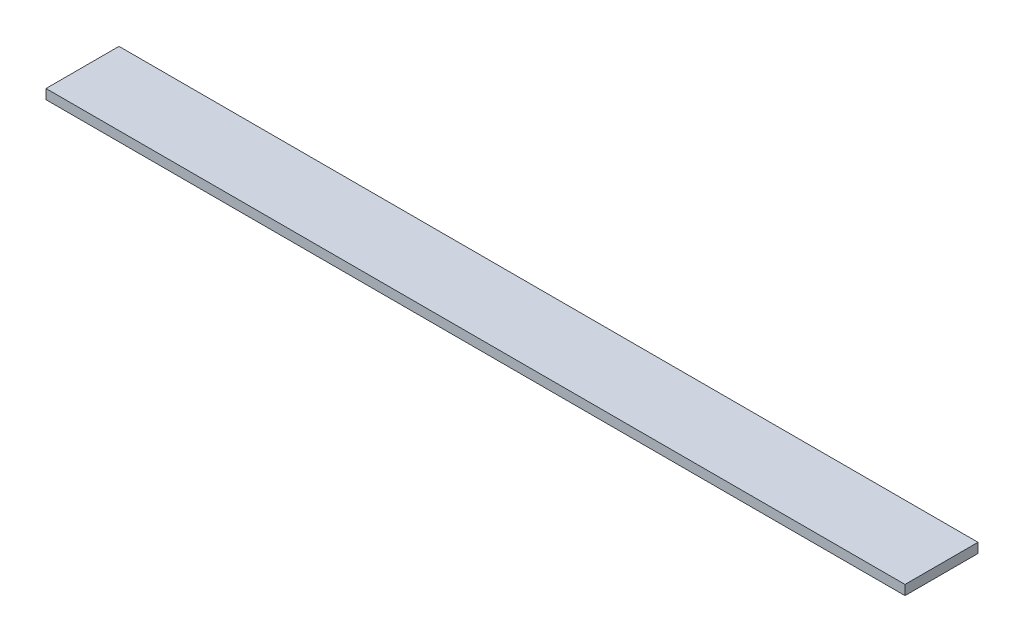
from build123d import *

# Parameters (mm, degrees)
SKETCH_1_W      = 30
SKETCH_1_H      = 4
EXTRUDE_1_DEPTH = 353


with BuildPart() as part:
    # Эскиз1 → Бобышка-Вытянуть1 (new body)
    with BuildSketch(Plane(origin=(0, 0, 0), x_dir=(0, 0, -1), z_dir=(1, 0, 0))):
        Rectangle(SKETCH_1_W, SKETCH_1_H)
    extrude(amount=EXTRUDE_1_DEPTH)


solid = part.part
